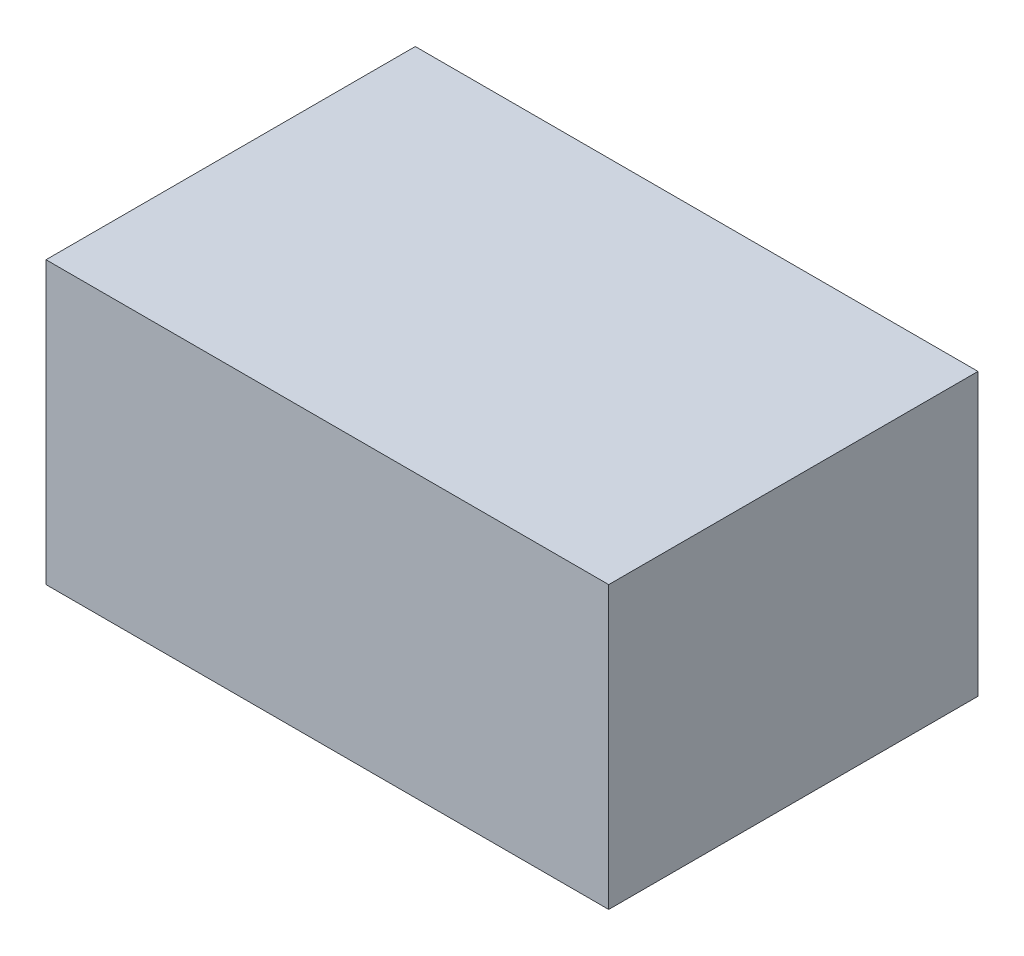
from build123d import *

# Parameters (mm, degrees)
SKETCH1_W           = 203.2
SKETCH1_H           = 133.35
BOSS_EXTRUDE1_DEPTH = 101.6


with BuildPart() as part:
    # Sketch1 → Boss-Extrude1 (new body)
    with BuildSketch(Plane(origin=(0, 0, 0), x_dir=(1, 0, 0), z_dir=(0, 1, 0))):
        Rectangle(SKETCH1_W, SKETCH1_H)
    extrude(amount=BOSS_EXTRUDE1_DEPTH)


solid = part.part
